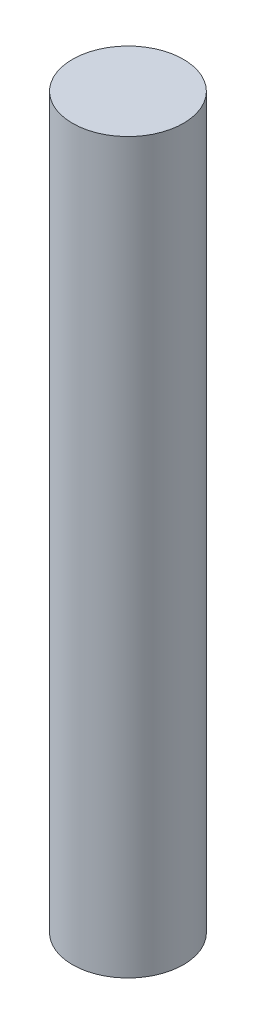
from build123d import *

# Parameters (mm, degrees)
SKETCH1_R           = 40.4114
BOSS_EXTRUDE1_DEPTH = 530.86


with BuildPart() as part:
    # Sketch1 → Boss-Extrude1 (new body)
    with BuildSketch(Plane(origin=(0, 0, 0), x_dir=(1, 0, 0), z_dir=(0, 1, 0))):
        Circle(SKETCH1_R)
    extrude(amount=BOSS_EXTRUDE1_DEPTH)


solid = part.part
